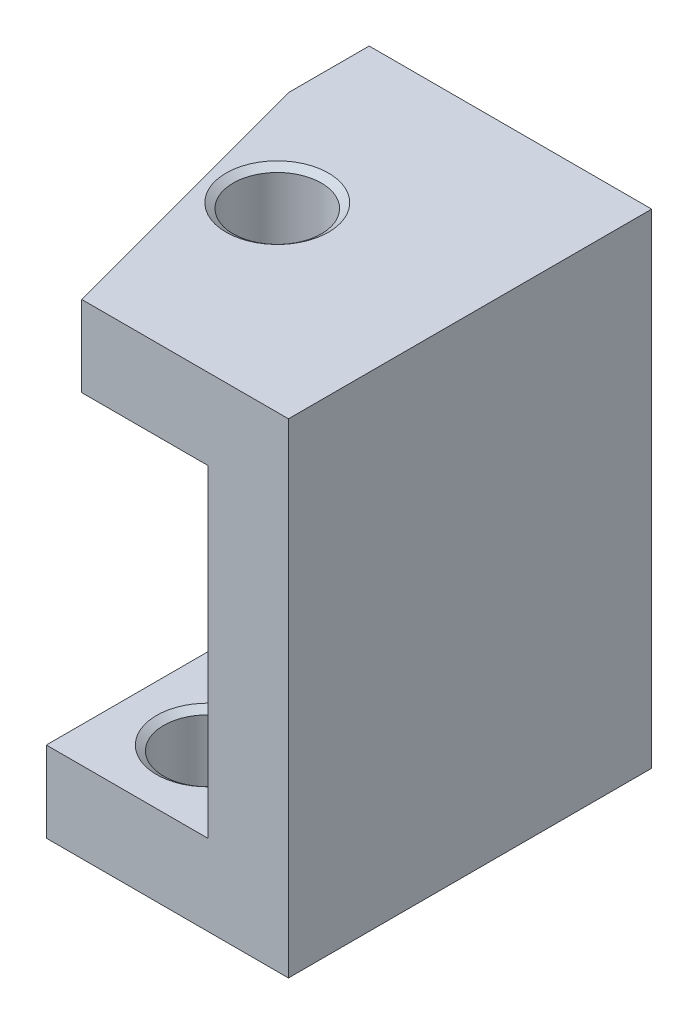
from build123d import *

# Parameters (mm, degrees)
SKETCH_1_W                   = 25
SKETCH_1_H                   = 12
SKETCH_1_W_2                 = 21
SKETCH_1_H_2                 = 8
EXTRUDE_1_DEPTH              = 9
CUT_EXTRUDE_1_DEPTH          = 10
CHAMFER_1_SIZE               = 7
CHAMFER_1_SIZE2              = 1.875644347
HOLE_WIZARD_2_561_AT_2_COUNT = 2
HOLE_WIZARD_2_561_AT_2_PITCH = 5


with BuildPart() as part:
    # Эскиз1 → Бобышка-Вытянуть1 (new body)
    with BuildSketch(Plane.XY):
        with Locations((12.5, 6)):
            Rectangle(SKETCH_1_W, SKETCH_1_H)
        with Locations((12.5, 6)):
            Rectangle(SKETCH_1_W_2, SKETCH_1_H_2, mode=Mode.SUBTRACT)
    extrude(amount=EXTRUDE_1_DEPTH)

    # Эскиз2 → Вырез-Вытянуть1 (cut, through all)
    with BuildSketch(Plane.XY.offset(9)):
        Polygon((18, 10), (18, 12), (0, 12), (0, 0), (19, 0), (19, 2), (2, 2), (2, 10), align=None)
    extrude(amount=-CUT_EXTRUDE_1_DEPTH, mode=Mode.SUBTRACT)

    # Фаска1
    chamfer_1_edges = [part.edges().sort_by_distance(p)[0] for p in [
        (18, 11, 9),
    ]]
    chamfer_1_side = [part.faces().sort_by_distance(p)[0] for p in [
        (18, 11, 4.5),
    ]]
    chamfer(chamfer_1_edges, length=CHAMFER_1_SIZE, length2=CHAMFER_1_SIZE2, reference=chamfer_1_side[0])

    # Эскиз5 → Отверстие обработанное метчиком #2-561 (revolve, cut)
    with BuildSketch(Plane(origin=(21, 0, 2), x_dir=(0, 0, -1), z_dir=(1, 0, 0))):
        Polygon((0, 0), (0, 2), (1.27, 2), (1.0922, 1.8755031), (1.0922, 0.1244969), (1.27, 0), align=None)
    hole_wizard_2_561 = revolve(axis=Axis((21, -6.35, 2), (0, 1, 0)), mode=Mode.SUBTRACT)

    # Отверстие обработанное метчиком #2-561 at 2: Отверстие обработанное метчиком #2-561 ×2
    with Locations(*[(0, 0, i * HOLE_WIZARD_2_561_AT_2_PITCH) for i in range(1, HOLE_WIZARD_2_561_AT_2_COUNT)]):
        add(hole_wizard_2_561, mode=Mode.SUBTRACT)

    # Эскиз6 → Отверстие обработанное метчиком #2-562 (revolve, cut)
    with BuildSketch(Plane(origin=(20.222787252, 12, 4.5), x_dir=(0, 0, 1), z_dir=(1, 0, 0))):
        Polygon((0, 0), (0, 2), (1.27, 2), (1.0922, 1.8755031), (1.0922, 0.1244969), (1.27, 0), align=None)
    revolve(axis=Axis((20.222787252, 18.35, 4.5), (0, -1, 0)), mode=Mode.SUBTRACT)


solid = part.part
